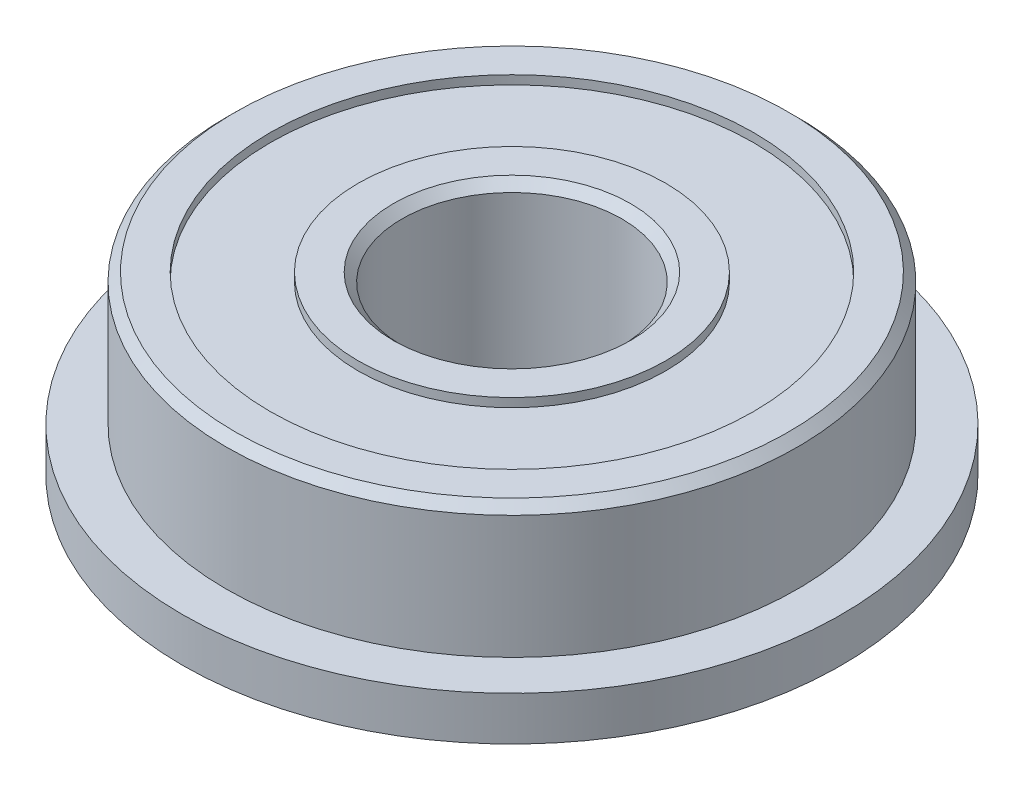
from build123d import *

# Parameters (mm, degrees)
SKETCH3_R          = 5.5
SKETCH3_R_2        = 3.5
CUT_EXTRUDE1_DEPTH = 0.2
CHAMFER1_SIZE      = 0.2


with BuildPart() as part:
    # Sketch2 → Revolve1 (revolve)
    with BuildSketch(Plane.XY):
        Polygon((-6.5, 4), (-2.5, 4), (-2.5, 0), (-7.5, 0), (-7.5, 1), (-6.5, 1), align=None)
    revolve(axis=Axis((0, 1.921623867, 0), (0, -1, 0)))

    # Sketch3 → Cut-Extrude1 (cut)
    with BuildSketch(Plane(origin=(0, 4, 0), x_dir=(1, 0, 0), z_dir=(0, 1, 0))):
        Circle(SKETCH3_R)
        Circle(SKETCH3_R_2, mode=Mode.SUBTRACT)
    cut_extrude1 = extrude(amount=-CUT_EXTRUDE1_DEPTH, mode=Mode.SUBTRACT)

    # Mirror1: Cut-Extrude1 across plane
    add(cut_extrude1.mirror(Plane.ZX.offset(2)), mode=Mode.SUBTRACT)

    # Chamfer1
    chamfer1_edges = [part.edges().sort_by_distance(p)[0] for p in [
        (2.5, 0, 0),
        (2.5, 4, 0),
        (6.5, 4, 0),
    ]]
    chamfer(chamfer1_edges, length=CHAMFER1_SIZE)


solid = part.part
